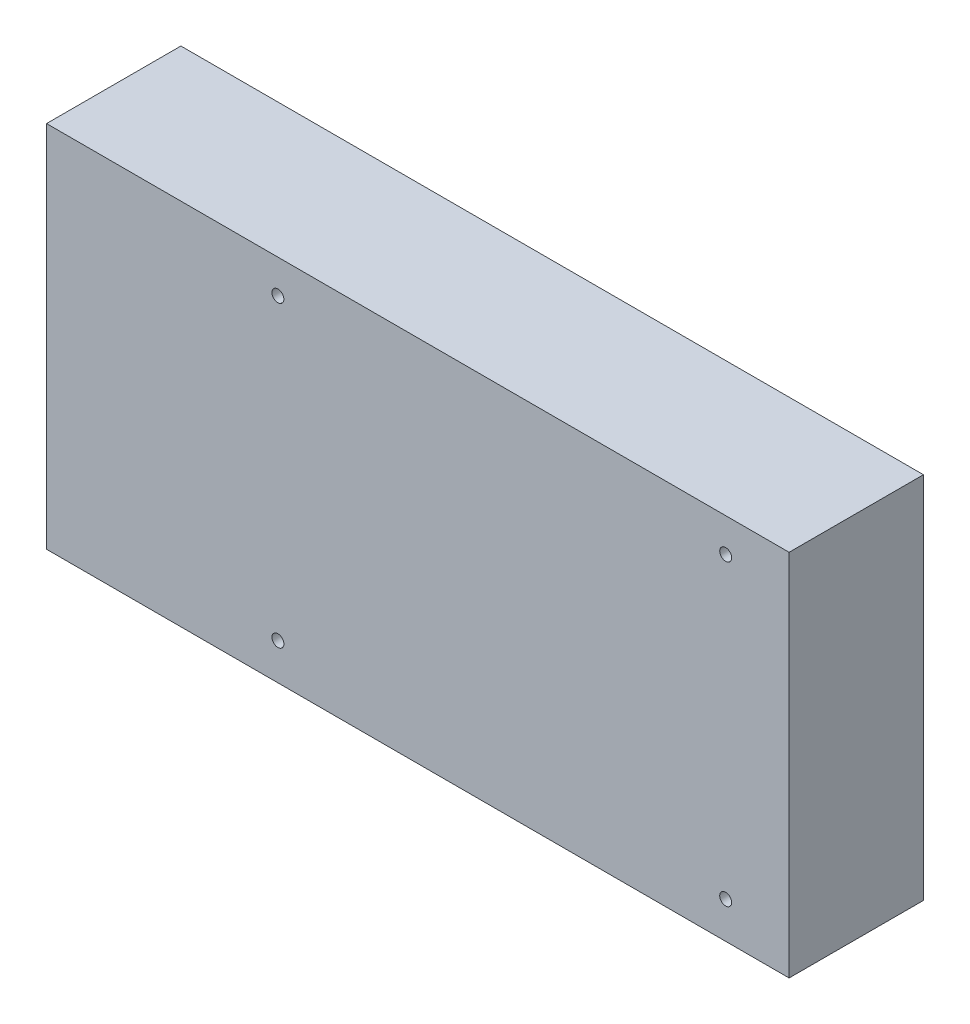
from build123d import *

# Parameters (mm, degrees)
SKETCH1_W            = 199
SKETCH1_H            = 98.806
BOSS_EXTRUDE1_DEPTH  = 36
SKETCH2_R            = 1.6
CUT_EXTRUDE1_DEPTH   = 37
LPATTERN1_COUNT      = 2
LPATTERN1_PITCH      = 120
LPATTERN1_COUNT_DIR2 = 2
LPATTERN1_PITCH_DIR2 = 80


with BuildPart() as part:
    # Sketch1 → Boss-Extrude1 (new body)
    with BuildSketch(Plane.XY):
        Rectangle(SKETCH1_W, SKETCH1_H)
    extrude(amount=BOSS_EXTRUDE1_DEPTH)

    # Sketch2 → Cut-Extrude1 (cut, through all)
    with BuildSketch(Plane.XY.offset(36)):
        with Locations((-37.5, 40.403)):
            Circle(SKETCH2_R)
    cut_extrude1 = extrude(amount=-CUT_EXTRUDE1_DEPTH, mode=Mode.SUBTRACT)

    # LPattern1: Cut-Extrude1 2 × 2
    with Locations(*[(i * LPATTERN1_PITCH, -j * LPATTERN1_PITCH_DIR2, 0) for i in range(LPATTERN1_COUNT) for j in range(LPATTERN1_COUNT_DIR2) if (i, j) != (0, 0)]):
        add(cut_extrude1, mode=Mode.SUBTRACT)


solid = part.part
